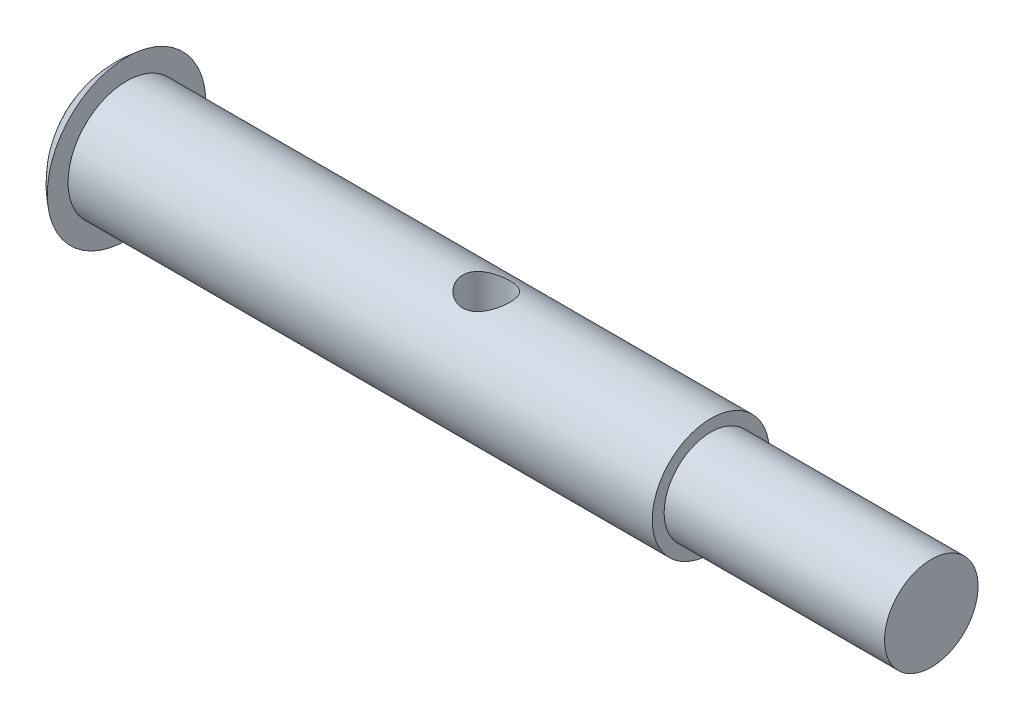
from build123d import *

# Parameters (mm, degrees)
SKETCH4_R               = 0.9906
CUT_EXTRUDE1_DEPTH      = 4.3274
CUT_EXTRUDE1_DEPTH_BACK = 4.3274


with BuildPart() as part:
    # Sketch1 → Revolve1 (revolve)
    with BuildSketch(Plane.XY):
        with BuildLine():
            Line((0, 3.3274), (0, 2.45745))
            Line((0, 2.45745), (24.511, 2.45745))
            Line((24.511, 2.45745), (24.511, 1.96215))
            Line((24.511, 1.96215), (33.7566, 1.96215))
            Line((33.7566, 1.96215), (33.7566, 0))
            Line((33.7566, 0), (-1.651, 0))
            ThreePointArc((-1.651, 0), (-1.21556162, 1.857242025), (0, 3.3274))
        make_face()
    revolve(axis=Axis((0, 0, 0), (1, 0, 0)))

    # Sketch4 → Cut-Extrude1 (cut, two sides)
    with BuildSketch(Plane(origin=(0, 0, 0), x_dir=(1, 0, 0), z_dir=(0, 1, 0))) as cut_extrude1_sk:
        with Locations((15.0876, 0)):
            Circle(SKETCH4_R)
    extrude(amount=CUT_EXTRUDE1_DEPTH, mode=Mode.SUBTRACT)
    extrude(cut_extrude1_sk.sketch, amount=-CUT_EXTRUDE1_DEPTH_BACK, mode=Mode.SUBTRACT)


solid = part.part
